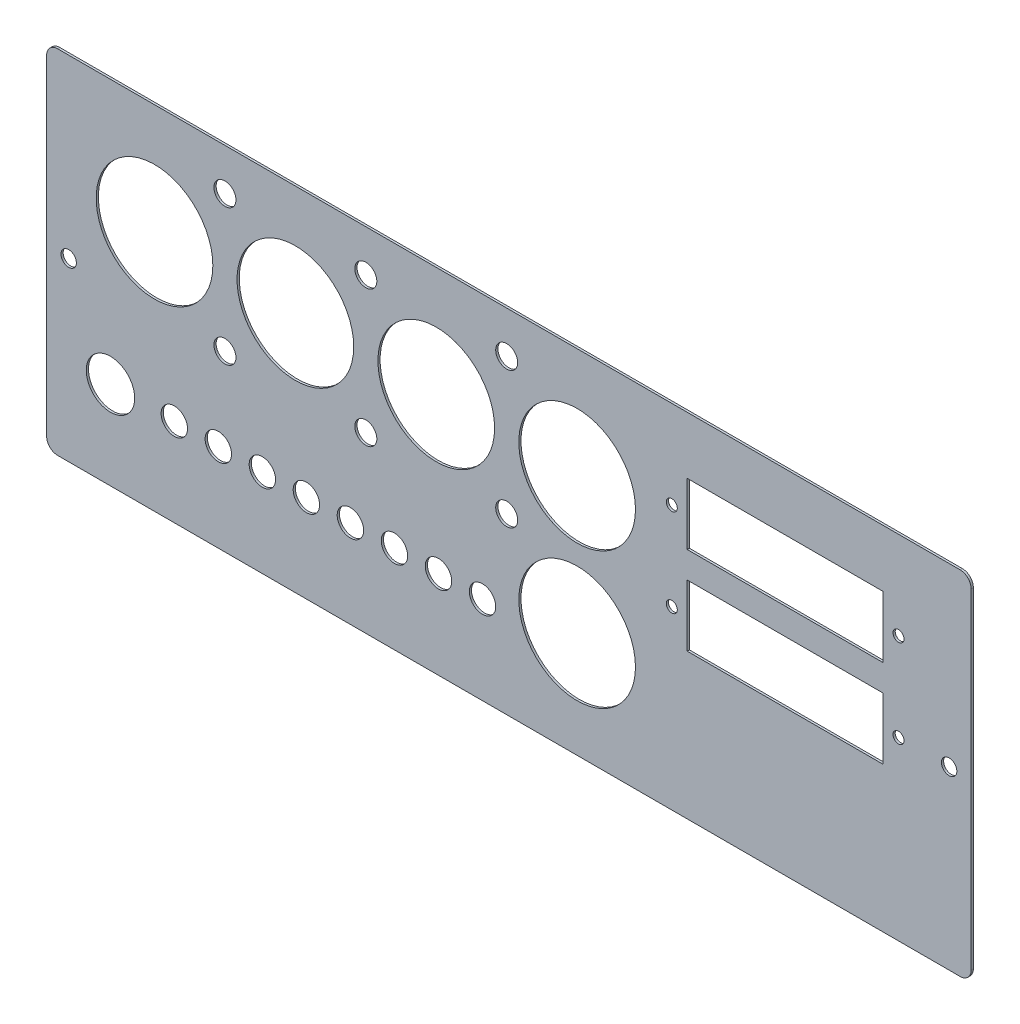
from build123d import *

# Parameters (mm, degrees)
ESQUISSE1_R        = 26.5
ESQUISSE1_R_2      = 2.5
ESQUISSE1_R_3      = 5
ESQUISSE1_R_4      = 11
ESQUISSE1_R_5      = 6
ESQUISSE1_R_6      = 3.5
ESQUISSE1_W        = 89
ESQUISSE1_H        = 28
BOSS_EXTRU_1_DEPTH = 1


with BuildPart() as part:
    # Esquisse1 → Boss.-Extru.1 (new body)
    with BuildSketch(Plane.XY):
        with BuildLine():
            Line((205, 80), (-205, 80))
            ThreePointArc((-205, 80), (-208.535533906, 78.535533906), (-210, 75))
            Line((-210, 75), (-210, -75))
            ThreePointArc((-210, -75), (-208.535533906, -78.535533906), (-205, -80))
            Line((-205, -80), (205, -80))
            ThreePointArc((205, -80), (208.535533906, -78.535533906), (210, -75))
            Line((210, -75), (210, 75))
            ThreePointArc((210, 75), (208.535533906, 78.535533906), (205, 80))
        make_face()
        with Locations((-161, 30)):
            Circle(ESQUISSE1_R, mode=Mode.SUBTRACT)
        with Locations((-97, 30)):
            Circle(ESQUISSE1_R, mode=Mode.SUBTRACT)
        with Locations((-33, 30)):
            Circle(ESQUISSE1_R, mode=Mode.SUBTRACT)
        with Locations((31, 30)):
            Circle(ESQUISSE1_R, mode=Mode.SUBTRACT)
        with Locations((74, 40)):
            Circle(ESQUISSE1_R_2, mode=Mode.SUBTRACT)
        with Locations((74, 0)):
            Circle(ESQUISSE1_R_2, mode=Mode.SUBTRACT)
        with Locations((177, 0)):
            Circle(ESQUISSE1_R_2, mode=Mode.SUBTRACT)
        with Locations((177, 40)):
            Circle(ESQUISSE1_R_2, mode=Mode.SUBTRACT)
        with Locations((31, -32)):
            Circle(ESQUISSE1_R, mode=Mode.SUBTRACT)
        with Locations((-129, 61)):
            Circle(ESQUISSE1_R_3, mode=Mode.SUBTRACT)
        with Locations((-65, 61)):
            Circle(ESQUISSE1_R_3, mode=Mode.SUBTRACT)
        with Locations((-1, 61)):
            Circle(ESQUISSE1_R_3, mode=Mode.SUBTRACT)
        with Locations((-1, -1)):
            Circle(ESQUISSE1_R_3, mode=Mode.SUBTRACT)
        with Locations((-65, -1)):
            Circle(ESQUISSE1_R_3, mode=Mode.SUBTRACT)
        with Locations((-129, -1)):
            Circle(ESQUISSE1_R_3, mode=Mode.SUBTRACT)
        with Locations((-181, -40)):
            Circle(ESQUISSE1_R_4, mode=Mode.SUBTRACT)
        with Locations((-152, -40)):
            Circle(ESQUISSE1_R_5, mode=Mode.SUBTRACT)
        with Locations((200, 0)):
            Circle(ESQUISSE1_R_6, mode=Mode.SUBTRACT)
        with Locations((-200, 0)):
            Circle(ESQUISSE1_R_6, mode=Mode.SUBTRACT)
        with Locations((-132, -40)):
            Circle(ESQUISSE1_R_5, mode=Mode.SUBTRACT)
        with Locations((-112, -40)):
            Circle(ESQUISSE1_R_5, mode=Mode.SUBTRACT)
        with Locations((-92, -40)):
            Circle(ESQUISSE1_R_5, mode=Mode.SUBTRACT)
        with Locations((-72, -40)):
            Circle(ESQUISSE1_R_5, mode=Mode.SUBTRACT)
        with Locations((-52, -40)):
            Circle(ESQUISSE1_R_5, mode=Mode.SUBTRACT)
        with Locations((-32, -40)):
            Circle(ESQUISSE1_R_5, mode=Mode.SUBTRACT)
        with Locations((-12, -40)):
            Circle(ESQUISSE1_R_5, mode=Mode.SUBTRACT)
        with Locations((125.5, 40)):
            Rectangle(ESQUISSE1_W, ESQUISSE1_H, mode=Mode.SUBTRACT)
        with Locations((125.5, 0)):
            Rectangle(ESQUISSE1_W, ESQUISSE1_H, mode=Mode.SUBTRACT)
    extrude(amount=BOSS_EXTRU_1_DEPTH)


solid = part.part
